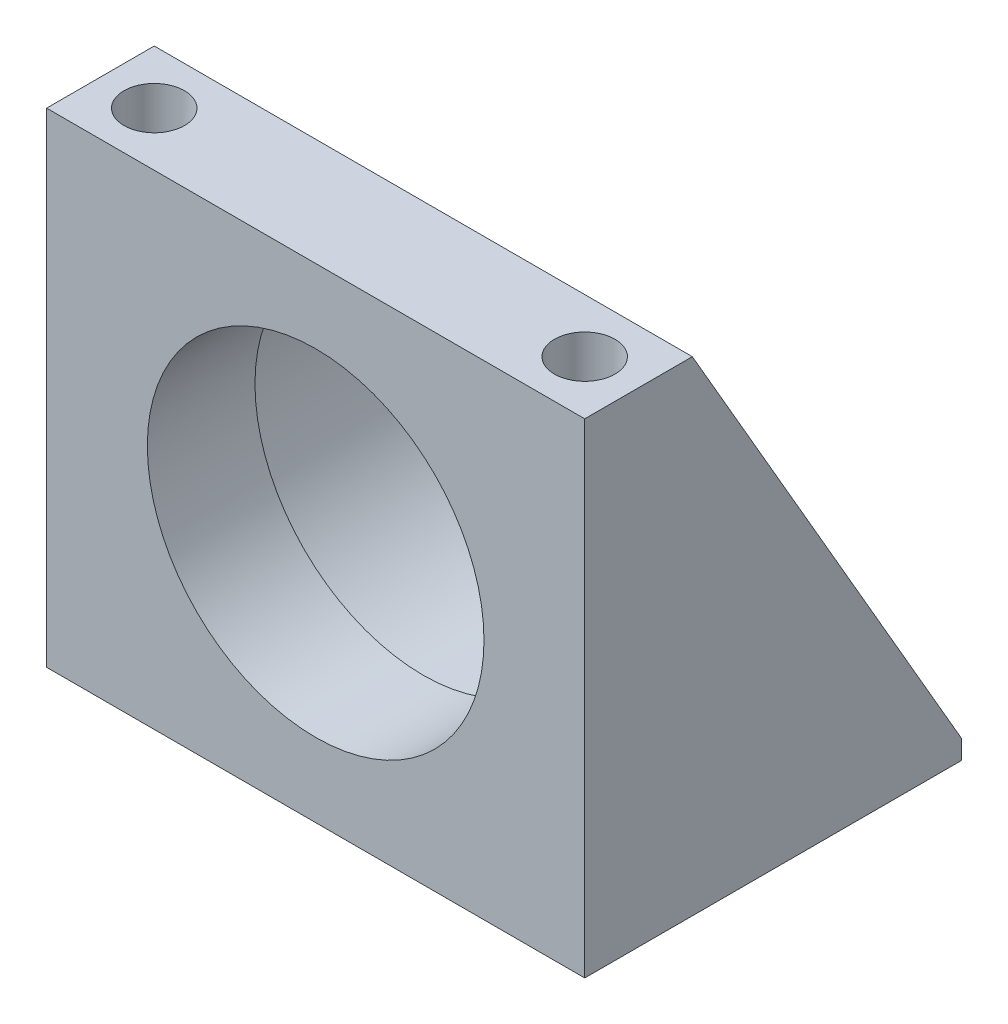
from build123d import *

# Parameters (mm, degrees)
SKETCH1_W          = 63.5
SKETCH1_H          = 57.15
SKETCH1_R          = 19.8628
EXTRUDE1_DEPTH     = 44.45
CUT_EXTRUDE1_DEPTH = 64.5
SKETCH3_R          = 22.225
CUT_EXTRUDE2_DEPTH = 31.75
FILLET1_R          = 1.524
HOLE1_D            = 7.1374
HOLE1_DEPTH        = 57.15


with BuildPart() as part:
    # Sketch1 → Extrude1 (new body)
    with BuildSketch(Plane.XY):
        with Locations((0, 28.575)):
            Rectangle(SKETCH1_W, SKETCH1_H)
        with Locations((0, 28.575)):
            Circle(SKETCH1_R, mode=Mode.SUBTRACT)
    extrude(amount=-EXTRUDE1_DEPTH)

    # Sketch2 → Cut-Extrude1 (cut, through all)
    with BuildSketch(Plane(origin=(31.75, 0, 0), x_dir=(0, 0, -1), z_dir=(1, 0, 0))):
        Polygon((12.7, 57.15), (44.45, 2.286), (44.45, 57.15), align=None)
    extrude(amount=-CUT_EXTRUDE1_DEPTH, mode=Mode.SUBTRACT)

    # Sketch3 → Cut-Extrude2 (cut)
    with BuildSketch(Plane(origin=(0, 0, -44.45), x_dir=(-1, 0, 0), z_dir=(0, 0, -1))):
        with Locations(Location((0, 28.575, 0), (0, 0, 270))):  # turned: the seam where the file's is
            Circle(SKETCH3_R)
    extrude(amount=-CUT_EXTRUDE2_DEPTH, mode=Mode.SUBTRACT)

    # Fillet1
    fillet1_edges = [part.edges().sort_by_distance(p)[0] for p in [
        (0, 50.8, -12.7),
    ]]
    fillet(fillet1_edges, radius=FILLET1_R)

    # Hole1
    with Locations(Plane(origin=(0, 57.15, 0), x_dir=(-1, 0, 0), z_dir=(0, 1, 0))):
        with Locations((25.4, -6.35), (-25.4, -6.35)):
            Hole(HOLE1_D / 2, depth=HOLE1_DEPTH)


solid = part.part
